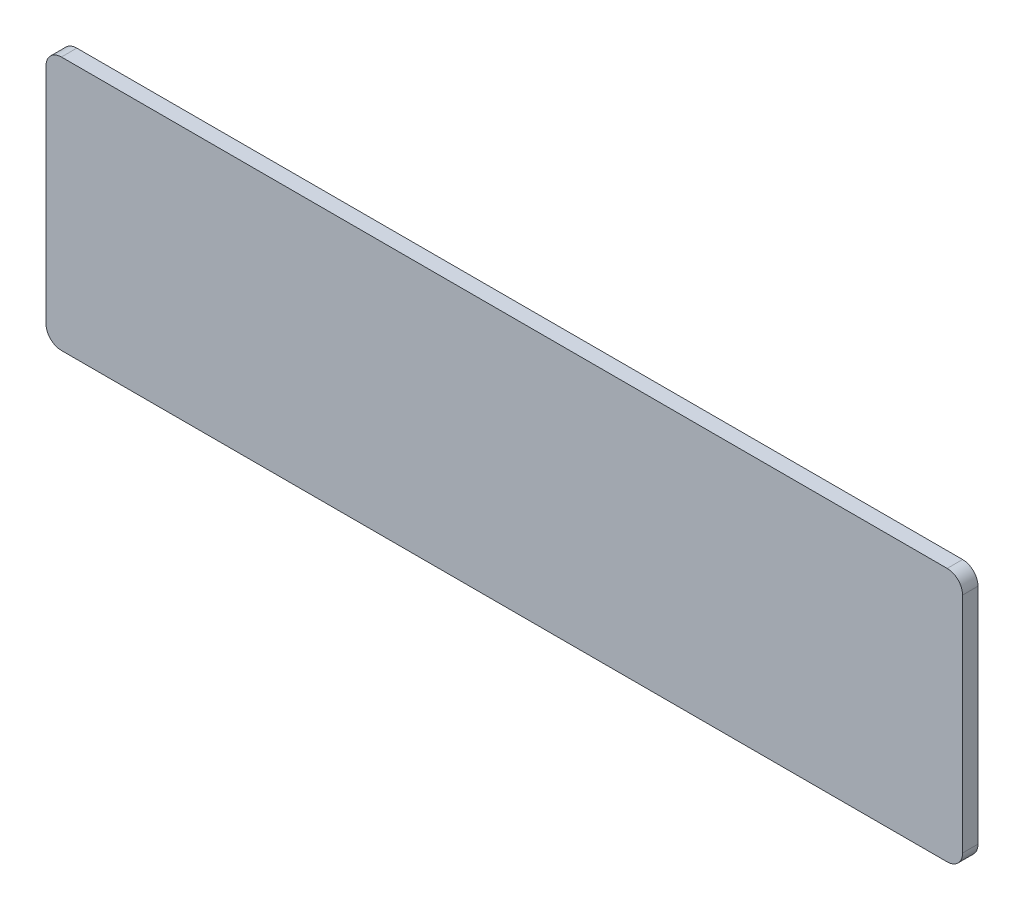
from build123d import *

# Parameters (mm, degrees)
DODANIE_WYCI_GNI_CIE1_DEPTH = 2
DODANIE_WYCI_GNI_CIE2_DEPTH = 1


with BuildPart() as part:
    # Szkic1 → Dodanie-wyciągnięcie1 (new body)
    with BuildSketch(Plane.XY):
        with BuildLine():
            Line((-57.5, -16.5), (57.5, -16.5))
            ThreePointArc((57.5, -16.5), (58.914213562, -15.914213562), (59.5, -14.5))
            Line((59.5, -14.5), (59.5, 14.5))
            ThreePointArc((59.5, 14.5), (58.914213562, 15.914213562), (57.5, 16.5))
            Line((57.5, 16.5), (-57.5, 16.5))
            ThreePointArc((-57.5, 16.5), (-58.914213562, 15.914213562), (-59.5, 14.5))
            Line((-59.5, 14.5), (-59.5, -14.5))
            ThreePointArc((-59.5, -14.5), (-58.914213562, -15.914213562), (-57.5, -16.5))
        make_face()
    extrude(amount=DODANIE_WYCI_GNI_CIE1_DEPTH)

    # Szkic4 → Dodanie-wyciągnięcie2 (add)
    with BuildSketch(Plane(origin=(0, 0, 0), x_dir=(-1, 0, 0), z_dir=(0, 0, -1))):
        with BuildLine():
            Line((53, -12), (-53, -12))
            ThreePointArc((-53, -12), (-54.414213562, -11.414213562), (-55, -10))
            Line((-55, -10), (-55, 10))
            ThreePointArc((-55, 10), (-54.414213562, 11.414213562), (-53, 12))
            Line((-53, 12), (53, 12))
            ThreePointArc((53, 12), (54.414213562, 11.414213562), (55, 10))
            Line((55, 10), (55, -10))
            ThreePointArc((55, -10), (54.414213562, -11.414213562), (53, -12))
        make_face()
    extrude(amount=DODANIE_WYCI_GNI_CIE2_DEPTH)


solid = part.part
